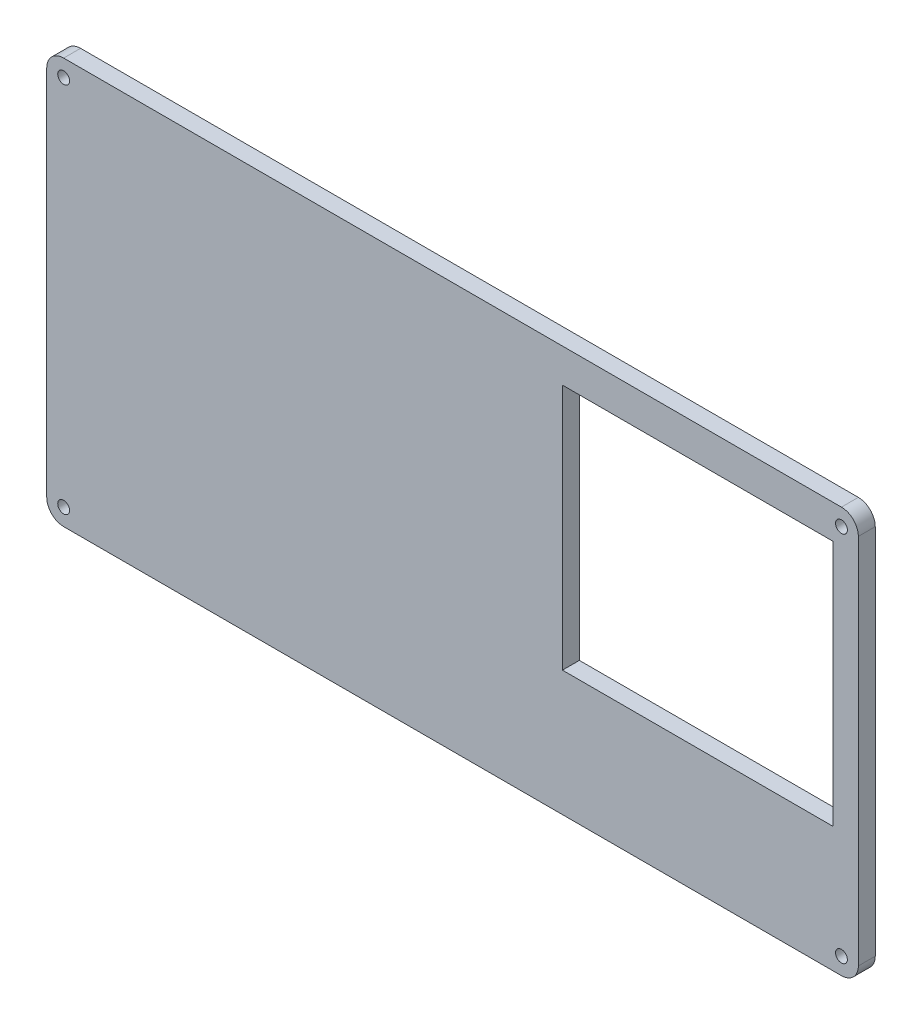
from build123d import *

# Parameters (mm, degrees)
BOSS_EXTRUDE1_DEPTH   = 5
SKETCH2_R             = 1.75
LUKNE_M3_VIJAKI_DEPTH = 5
SKETCH3_W             = 80
SKETCH3_H             = 73
CUT_EXTRUDE2_DEPTH    = 5


with BuildPart() as part:
    # Sketch1 → Boss-Extrude1 (new body)
    with BuildSketch(Plane.XY):
        with BuildLine():
            Line((-115, -60), (115, -60))
            ThreePointArc((115, -60), (118.535533906, -58.535533906), (120, -55))
            Line((120, -55), (120, 55))
            ThreePointArc((120, 55), (118.535533906, 58.535533906), (115, 60))
            Line((115, 60), (-115, 60))
            ThreePointArc((-115, 60), (-118.535533906, 58.535533906), (-120, 55))
            Line((-120, 55), (-120, -55))
            ThreePointArc((-120, -55), (-118.535533906, -58.535533906), (-115, -60))
        make_face()
    extrude(amount=BOSS_EXTRUDE1_DEPTH)

    # Sketch2 → lukne_m3_vijaki (cut)
    with BuildSketch(Plane.XY.offset(5)):
        with Locations((-115, 55)):
            Circle(SKETCH2_R)
        with Locations((115, 55)):
            Circle(SKETCH2_R)
        with Locations((115, -55)):
            Circle(SKETCH2_R)
        with Locations((-115, -55)):
            Circle(SKETCH2_R)
    extrude(amount=-LUKNE_M3_VIJAKI_DEPTH, mode=Mode.SUBTRACT)

    # Sketch3 → Cut-Extrude2 (cut)
    with BuildSketch(Plane.XY.offset(5)):
        with Locations((72.5, 13.5)):
            Rectangle(SKETCH3_W, SKETCH3_H)
    extrude(amount=-CUT_EXTRUDE2_DEPTH, mode=Mode.SUBTRACT)


solid = part.part
